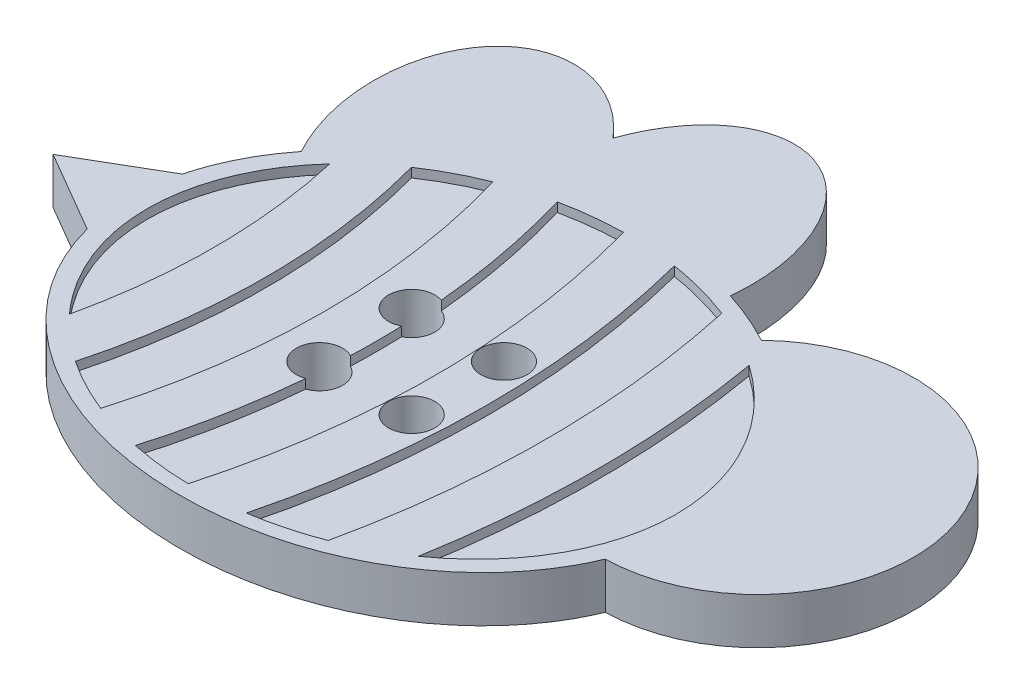
from build123d import *

# Parameters (mm, degrees)
BOSS_EXTRUDE1_DEPTH     = 1.5875
CUT_EXTRUDE1_DEPTH      = 0.3175
SKETCH3_R               = 0.79375
CUT_EXTRUDE2_DEPTH      = 1.0000001
CUT_EXTRUDE2_DEPTH_BACK = 2.5875001


with BuildPart() as part:
    # Sketch1 → Boss-Extrude1 (new body)
    with BuildSketch(Plane(origin=(0, 0, 0), x_dir=(1, 0, 0), z_dir=(0, 1, 0))):
        with BuildLine():
            Line((-9.528369768, 1.639294983), (-12.340817061, 0))
            Line((-12.340817061, 0), (-9.528369768, -1.639294983))
            add(Edge.make_bspline(
                [(-9.528369768, -1.639294983), (-2.204811325, -30.236444344), (9.222319401, -2.557832809)],
                knots=[3.348492087, 3.348492087, 3.348492087, 5.956894226, 5.956894226, 5.956894226], degree=2, weights=[1, 0.263448505, 1]))
            ThreePointArc((9.222319401, -2.557832809), (14.063669758, 4.861741942), (5.386142086, 6.647596434))
            add(Edge.make_bspline(
                [(5.386142086, 6.647596434), (4.510994131, 7.123954738), (3.532010247, 7.436330904)],
                knots=[0.98457357, 0.98457357, 0.98457357, 1.199549233, 1.199549233, 1.199549233], degree=2, weights=[1, 0.994228743, 1]))
            add(Edge.make_bspline(
                [(3.532010247, 7.436330904), (3.943488221, 11.723337295), (1.053739695, 12.87663719), (-1.836008832, 14.029937085), (-3.188772671, 10.118598293)],
                knots=[1.491893494, 1.491893494, 1.491893494, 2.899094673, 2.899094673, 4.306295852, 4.306295852, 4.306295852], degree=2, weights=[1, 0.762517671, 1, 0.762517671, 1]))
            add(Edge.make_bspline(
                [(-3.188772671, 10.118598293), (-5.87143665, 13.2540264), (-8.060026616, 10.715776402), (-10.248616582, 8.177526403), (-8.157449382, 4.356101045)],
                knots=[2.112509352, 2.112509352, 2.112509352, 3.547759064, 3.547759064, 4.983008777, 4.983008777, 4.983008777], degree=2, weights=[1, 0.75336974, 1, 0.75336974, 1]))
            add(Edge.make_bspline(
                [(-8.157449382, 4.356101045), (-9.153524987, 3.102994941), (-9.528369768, 1.639294983)],
                knots=[2.564153577, 2.564153577, 2.564153577, 2.93469322, 2.93469322, 2.93469322], degree=2, weights=[1, 0.982886582, 1]))
        make_face()
    extrude(amount=BOSS_EXTRUDE1_DEPTH)

    # Sketch2 → Cut-Extrude1 (cut)
    with BuildSketch(Plane(origin=(0, 1.5875, 0), x_dir=(1, 0, 0), z_dir=(0, 1, 0))):
        with BuildLine():
            ThreePointArc((-7.298705791, -4.479973882), (-6.798701603, 0), (-7.298705791, 4.479973882))
            add(Edge.make_bspline(
                [(-7.298705791, 4.479973882), (-11.359464807, 0), (-7.298705791, -4.479973882)],
                knots=[2.500720633, 2.500720633, 2.500720633, 3.782464674, 3.782464674, 3.782464674], degree=2, weights=[1, 0.801574686, 1]))
        make_face()
        with BuildLine():
            ThreePointArc((-5.790676448, -5.782468932), (-5.020701603, 0), (-5.790676448, 5.782468932))
            add(Edge.make_bspline(
                [(-3.952129393, 6.750320883), (-4.942394351, 6.357715693), (-5.790676448, 5.782468932)],
                knots=[2.019768206, 2.019768206, 2.019768206, 2.260043693, 2.260043693, 2.260043693], degree=2, weights=[1, 0.992792137, 1]))
            ThreePointArc((-3.952129393, 6.750320883), (-2.988701603, 0), (-3.952129393, -6.750320883))
            add(Edge.make_bspline(
                [(-5.790676448, -5.782468932), (-4.942394351, -6.357715693), (-3.952129393, -6.750320883)],
                knots=[4.023141614, 4.023141614, 4.023141614, 4.263417101, 4.263417101, 4.263417101], degree=2, weights=[1, 0.992792137, 1]))
        make_face()
        with BuildLine():
            ThreePointArc((-2.248928802, -7.260775771), (-1.210701603, 0), (-2.248928802, 7.260775771))
            add(Edge.make_bspline(
                [(-0.20165568, 7.491077276), (-1.241272948, 7.472126039), (-2.248928802, 7.260775771)],
                knots=[1.592944816, 1.592944816, 1.592944816, 1.820365865, 1.820365865, 1.820365865], degree=2, weights=[1, 0.993541921, 1]))
            ThreePointArc((-0.20165568, 7.491077276), (0.821298397, 0), (-0.20165568, -7.491077276))
            add(Edge.make_bspline(
                [(-2.248928802, -7.260775771), (-1.241272948, -7.472126039), (-0.20165568, -7.491077276)],
                knots=[4.462819442, 4.462819442, 4.462819442, 4.690240491, 4.690240491, 4.690240491], degree=2, weights=[1, 0.993541921, 1]))
        make_face()
        with BuildLine():
            ThreePointArc((1.672078379, -7.365494688), (2.599298397, 0), (1.672078379, 7.365494688))
            add(Edge.make_bspline(
                [(3.901033108, 6.77041789), (2.833471683, 7.186956173), (1.672078379, 7.365494688)],
                knots=[1.128044104, 1.128044104, 1.128044104, 1.386113557, 1.386113557, 1.386113557], degree=2, weights=[1, 0.991686564, 1]))
            ThreePointArc((3.901033108, 6.77041789), (4.631298397, 0), (3.901033108, -6.77041789))
            add(Edge.make_bspline(
                [(1.672078379, -7.365494688), (2.833471683, -7.186956173), (3.901033108, -6.77041789)],
                knots=[4.89707175, 4.89707175, 4.89707175, 5.155141203, 5.155141203, 5.155141203], degree=2, weights=[1, 0.991686564, 1]))
        make_face()
        with BuildLine():
            ThreePointArc((5.922748593, -5.691164458), (6.409298397, 0), (5.922748593, 5.691164458))
            add(Edge.make_bspline(
                [(5.922748593, -5.691164458), (13.998465453, 0), (5.922748593, 5.691164458)],
                knots=[5.420580545, 5.420580545, 5.420580545, 7.14579007, 7.14579007, 7.14579007], degree=2, weights=[1, 0.650461257, 1]))
        make_face()
    extrude(amount=-CUT_EXTRUDE1_DEPTH, mode=Mode.SUBTRACT)

    # Sketch3 → Cut-Extrude2 (cut, two sides)
    with BuildSketch(Plane(origin=(0, 1.5875, 0), x_dir=(1, 0, 0), z_dir=(0, 1, 0))) as cut_extrude2_sk:
        with Locations((-1.5875, 1.5875)):
            Circle(SKETCH3_R)
        with Locations((1.5875, 1.5875)):
            Circle(SKETCH3_R)
        with Locations((1.5875, -1.5875)):
            Circle(SKETCH3_R)
        with Locations((-1.5875, -1.5875)):
            Circle(SKETCH3_R)
    extrude(amount=CUT_EXTRUDE2_DEPTH, mode=Mode.SUBTRACT)
    extrude(cut_extrude2_sk.sketch, amount=-CUT_EXTRUDE2_DEPTH_BACK, mode=Mode.SUBTRACT)


solid = part.part
